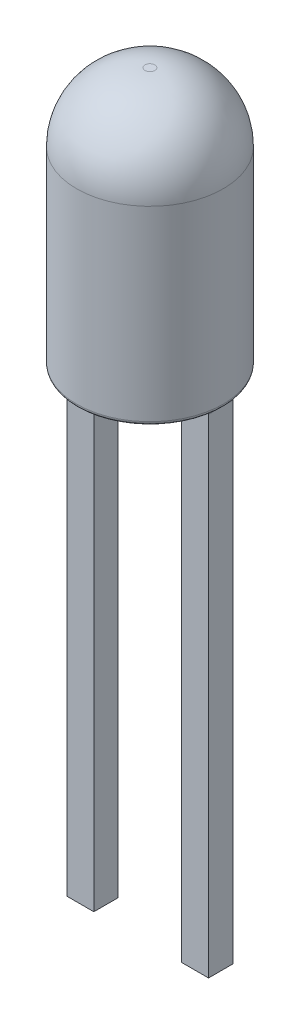
from build123d import *

# Parameters (mm, degrees)
SKETCH2_R                  = 1.5
BOSS_EXTRUDE1_DEPTH        = 5.3
FILLET1_R                  = 1.4
BOSS_EXTRUDE2_DEPTH        = 0.25
BOSS_EXTRUDE2_DEPTH_BACK   = 0.25
BOSS_EXTRUDE2_2_DEPTH      = 0.25
BOSS_EXTRUDE2_2_DEPTH_BACK = 0.25
SKETCH4_W                  = 0.55
SKETCH4_H                  = 0.5
BOSS_EXTRUDE3_DEPTH        = 10
BOSS_EXTRUDE3_2_DEPTH      = 10
FILLET2_R                  = 0.05
FILLET3_R                  = 0.08


with BuildPart() as part:
    # Sketch2 → Boss-Extrude1 (new body)
    with BuildSketch(Plane(origin=(0, 0, 0), x_dir=(1, 0, 0), z_dir=(0, 1, 0))):
        Circle(SKETCH2_R)
    extrude(amount=BOSS_EXTRUDE1_DEPTH)

    # Fillet1
    fillet1_edges = [part.edges().sort_by_distance(p)[0] for p in [
        (-1.5, 5.3, 0),
    ]]
    fillet(fillet1_edges, radius=FILLET1_R)

    # Fillet3
    fillet3_edges = [part.edges().sort_by_distance(p)[0] for p in [
        (-1.5, 0, 0),
    ]]
    fillet(fillet3_edges, radius=FILLET3_R)


with BuildPart() as body_2:
    # Sketch3 → Boss-Extrude2 (new, two sides: drawn at the far end of the back side and taken through both)
    with BuildSketch(Plane.XY.offset(-BOSS_EXTRUDE2_DEPTH_BACK)):
        Polygon((-1.45, 2.6), (-1.45, 0), (-0.9, 0), (-0.9, 0.6), (-0.624114196, 0.6), (-0.624114196, 0.82503781), (-1.225355096, 2.6), align=None)
    extrude(amount=BOSS_EXTRUDE2_DEPTH + BOSS_EXTRUDE2_DEPTH_BACK)


with BuildPart() as body_3:
    # Sketch3 → Boss-Extrude2 2 (new, two sides: drawn at the far end of the back side and taken through both)
    with BuildSketch(Plane.XY.offset(-BOSS_EXTRUDE2_2_DEPTH_BACK)):
        Polygon((1.45, 2.6), (-0.872452828, 2.6), (0.496677266, 0.6), (0.9, 0.6), (0.9, 0), (1.45, 0), align=None)
    extrude(amount=BOSS_EXTRUDE2_2_DEPTH + BOSS_EXTRUDE2_2_DEPTH_BACK)

    # Sketch5 → Cut-Revolve1 (revolve, cut)
    with BuildSketch(Plane(origin=(0, 0, 0), x_dir=(0, 0, -1), z_dir=(1, 0, 0))):
        Polygon((0, 2.6), (0, 2.3), (-0.6, 2.6), align=None)
    revolve(axis=Axis((0, 2.6, 0), (0, -1, 0)), mode=Mode.SUBTRACT)


with BuildPart() as body_4:
    # Sketch4 → Boss-Extrude3 (new body)
    with BuildSketch(Plane(origin=(0, 0, 0), x_dir=(-1, 0, 0), z_dir=(0, -1, 0))):
        with Locations((1.175, 0)):
            Rectangle(SKETCH4_W, SKETCH4_H)
    extrude(amount=BOSS_EXTRUDE3_DEPTH)


with BuildPart() as body_5:
    # Sketch4 → Boss-Extrude3 2 (new body)
    with BuildSketch(Plane(origin=(0, 0, 0), x_dir=(-1, 0, 0), z_dir=(0, -1, 0))):
        with Locations((-1.175, 0)):
            Rectangle(SKETCH4_W, SKETCH4_H)
    extrude(amount=BOSS_EXTRUDE3_2_DEPTH)


with BuildPart() as body_6:
    # Sketch5_3 → Revolve1 (revolve)
    with BuildSketch(Plane(origin=(0, 0, 0), x_dir=(0, 0, -1), z_dir=(1, 0, 0))):
        Polygon((0, 2.6), (0, 2.3), (-0.6, 2.6), align=None)
    revolve(axis=Axis((0, 2.6, 0), (0, -1, 0)))

    # Fillet2
    fillet2_edges = [body_6.edges().sort_by_distance(p)[0] for p in [
        (0, 2.6, -0.6),
    ]]
    fillet(fillet2_edges, radius=FILLET2_R)


solid = Compound([part.part, body_2.part, body_3.part, body_4.part, body_5.part, body_6.part])
